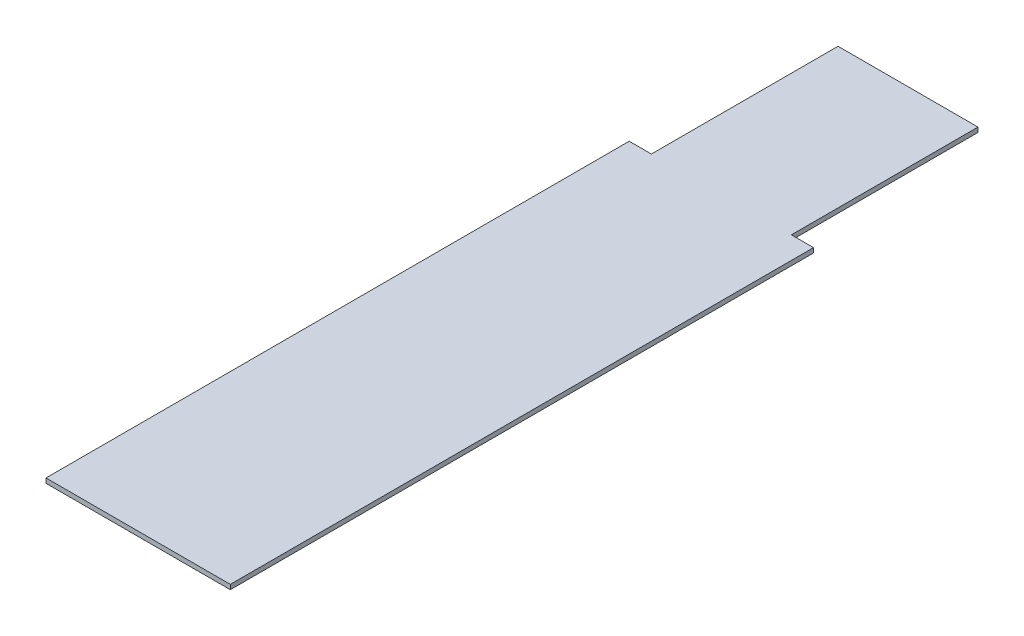
from build123d import *

# Parameters (mm, degrees)
AUFSATZ_LINEAR_AUSTRAGEN1_DEPTH = 0.2


with BuildPart() as part:
    # Skizze1 → Aufsatz-Linear austragen1 (new body)
    with BuildSketch(Plane(origin=(0, 0, 0), x_dir=(1, 0, 0), z_dir=(0, 1, 0))):
        Polygon((-3, 12.5), (-3.95, 12.5), (-3.95, -12.5), (3.95, -12.5), (3.95, 12.5), (3, 12.5), (3, 20.5), (-3, 20.5), align=None)
    extrude(amount=AUFSATZ_LINEAR_AUSTRAGEN1_DEPTH)


solid = part.part
